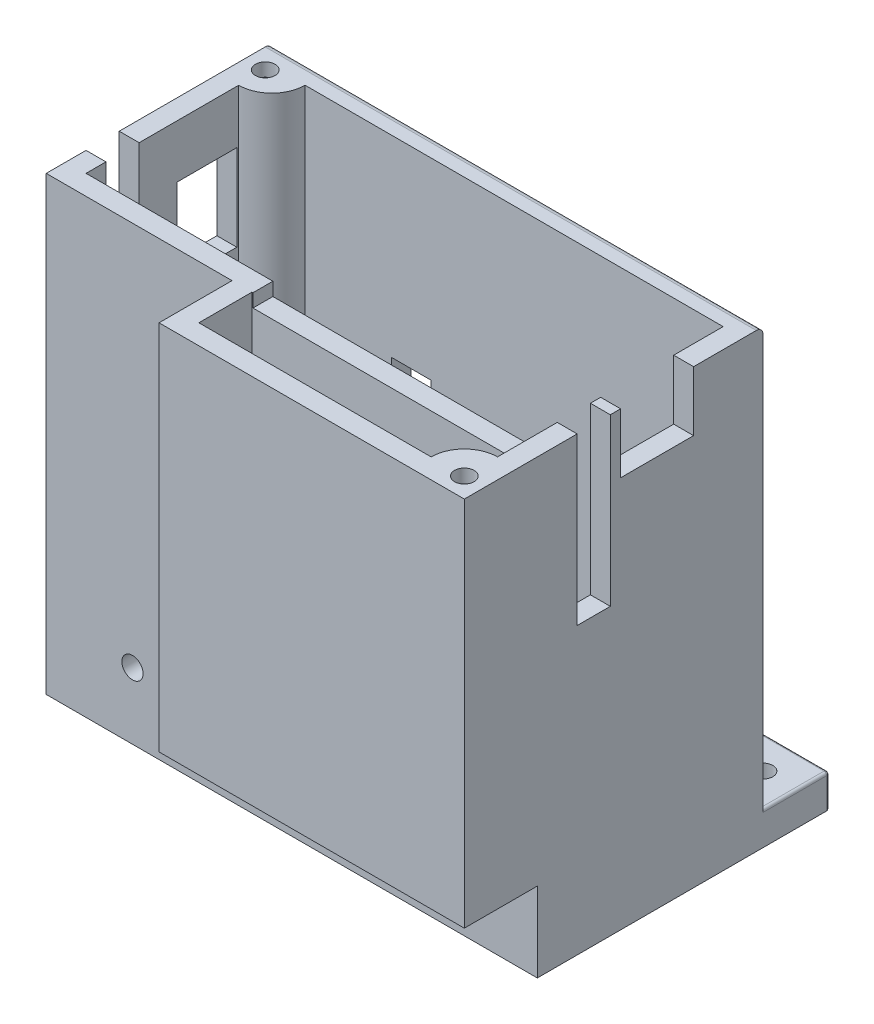
from build123d import *

# Parameters (mm, degrees)
SKETCH1_W            = 74
SKETCH1_H            = 45
BOSS_EXTRUDE1_DEPTH  = 68
SKETCH3_W            = 68
SKETCH3_H            = 39
CUT_EXTRUDE2_DEPTH   = 65
SKETCH13_W           = 68
SKETCH13_H           = 3
BOSS_EXTRUDE3_DEPTH  = 65
SKETCH14_W           = 5
SKETCH14_H           = 58
CUT_EXTRUDE5_DEPTH   = 23
SKETCH15_W           = 5
SKETCH15_H           = 25
CUT_EXTRUDE6_DEPTH   = 3
SKETCH18_R           = 1.6
CUT_EXTRUDE8_DEPTH   = 3
SKETCH20_R           = 4
CUT_EXTRUDE9_DEPTH   = 18
BOSS_EXTRUDE4_DEPTH  = 68
SKETCH23_R           = 1.6
CUT_EXTRUDE10_DEPTH  = 66
BOSS_EXTRUDE5_DEPTH  = 68
SKETCH25_R           = 1.6
CUT_EXTRUDE11_DEPTH  = 66
FILLET2_R            = 1
SKETCH30_W           = 10
SKETCH30_H           = 5
BOSS_EXTRUDE6_DEPTH  = 10
SKETCH33_R           = 1.48
CUT_EXTRUDE13_DEPTH  = 5
SKETCH34_W           = 10
SKETCH34_H           = 5
BOSS_EXTRUDE8_DEPTH  = 10
SKETCH35_R           = 1.48
CUT_EXTRUDE14_DEPTH  = 5
FILLET10_R           = 0.4
CUT_EXTRUDE17_DEPTH  = 11
SKETCH45_W           = 3
SKETCH45_H           = 56
BOSS_EXTRUDE9_DEPTH  = 11
SKETCH47_W           = 46
SKETCH47_H           = 3
BOSS_EXTRUDE10_DEPTH = 11
SKETCH49_R           = 1.48
CUT_EXTRUDE18_DEPTH  = 56
SKETCH50_R           = 1.48
CUT_EXTRUDE19_DEPTH  = 68
SKETCH52_W           = 39.849234896
SKETCH52_H           = 2
CUT_EXTRUDE20_DEPTH  = 3
SKETCH54_W           = 11
SKETCH54_H           = 9
CUT_EXTRUDE21_DEPTH  = 3
SKETCH56_W           = 9
SKETCH56_H           = 13
CUT_EXTRUDE22_DEPTH  = 3
SKETCH57_W           = 6
SKETCH57_H           = 6
CUT_EXTRUDE23_DEPTH  = 3


with BuildPart() as part:
    # Sketch1 → Boss-Extrude1 (new body)
    with BuildSketch(Plane(origin=(-3.580186039, 0, -14.417736579), x_dir=(1, 0, 0), z_dir=(0, 1, 0))):
        with Locations((12.716824493, 5.25)):
            Rectangle(SKETCH1_W, SKETCH1_H)
    extrude(amount=BOSS_EXTRUDE1_DEPTH)

    # Sketch3 → Cut-Extrude2 (cut)
    with BuildSketch(Plane(origin=(-3.580186039, 68, -14.417736579), x_dir=(1, 0, 0), z_dir=(0, 1, 0))):
        with Locations((12.716824493, 5.25)):
            Rectangle(SKETCH3_W, SKETCH3_H)
    extrude(amount=-CUT_EXTRUDE2_DEPTH, mode=Mode.SUBTRACT)

    # Sketch13 → Boss-Extrude3 (add)
    with BuildSketch(Plane(origin=(-3.580186039, 3, -14.417736579), x_dir=(1, 0, 0), z_dir=(0, 1, 0))):
        with Locations((12.716824493, -4.75)):
            Rectangle(SKETCH13_W, SKETCH13_H)
    extrude(amount=BOSS_EXTRUDE3_DEPTH)

    # Sketch14 → Cut-Extrude5 (cut)
    with BuildSketch(Plane(origin=(-27.863361546, 0, -14.417736579), x_dir=(0, 0, 1), z_dir=(-1, 0, 0))):
        with Locations((-2.25, 39)):
            Rectangle(SKETCH14_W, SKETCH14_H)
    extrude(amount=-CUT_EXTRUDE5_DEPTH, mode=Mode.SUBTRACT)

    # Sketch15 → Cut-Extrude6 (cut)
    with BuildSketch(Plane(origin=(46.136638454, 0, -14.417736579), x_dir=(0, 0, -1), z_dir=(1, 0, 0))):
        with Locations((2.25, 55.5)):
            Rectangle(SKETCH15_W, SKETCH15_H)
    extrude(amount=-CUT_EXTRUDE6_DEPTH, mode=Mode.SUBTRACT)

    # Sketch18 → Cut-Extrude8 (cut)
    with BuildSketch(Plane(origin=(-3.580186039, 0, -11.167736579), x_dir=(-1, 0, 0), z_dir=(0, 0, -1))):
        with Locations((11.283175507, 10)):
            Circle(SKETCH18_R)
    extrude(amount=-CUT_EXTRUDE8_DEPTH, mode=Mode.SUBTRACT)

    # Sketch20 → Cut-Extrude9 (cut)
    with BuildSketch(Plane(origin=(0, 0, -42.167736579), x_dir=(-1, 0, 0), z_dir=(0, 0, -1))):
        with Locations((9.863361546, 8)):
            Circle(SKETCH20_R)
    extrude(amount=-CUT_EXTRUDE9_DEPTH, mode=Mode.SUBTRACT)

    # Sketch21 → Boss-Extrude4 (add)
    with BuildSketch(Plane.XZ):
        with BuildLine():
            Line((46.136638454, -4.167736579), (46.136638454, 2.832263421))
            Line((46.136638454, 2.832263421), (39.136638454, 2.832263421))
            ThreePointArc((39.136638454, 2.832263421), (39.601104548, -3.703270485), (46.136638454, -4.167736579))
        make_face()
    extrude(amount=-BOSS_EXTRUDE4_DEPTH)

    # Sketch23 → Cut-Extrude10 (cut)
    with BuildSketch(Plane.XZ):
        with Locations((43.136638454, -0.167736579)):
            Circle(SKETCH23_R)
    extrude(amount=-CUT_EXTRUDE10_DEPTH, mode=Mode.SUBTRACT)

    # Sketch24 → Boss-Extrude5 (add)
    with BuildSketch(Plane.XZ):
        with BuildLine():
            Line((-20.863361546, -42.167736579), (-27.863361546, -42.167736579))
            Line((-27.863361546, -42.167736579), (-27.863361546, -35.167736579))
            ThreePointArc((-27.863361546, -35.167736579), (-21.327827641, -35.632202673), (-20.863361546, -42.167736579))
        make_face()
    extrude(amount=-BOSS_EXTRUDE5_DEPTH)

    # Sketch25 → Cut-Extrude11 (cut)
    with BuildSketch(Plane.XZ):
        with Locations((-24.863361546, -39.167736579)):
            Circle(SKETCH25_R)
    extrude(amount=-CUT_EXTRUDE11_DEPTH, mode=Mode.SUBTRACT)

    # Fillet2
    fillet2_edges = [part.edges().sort_by_distance(p)[0] for p in [
        (9.136638454, 68, -42.167736579),
    ]]
    fillet(fillet2_edges, radius=FILLET2_R)

    # Sketch30 → Boss-Extrude6 (add)
    with BuildSketch(Plane(origin=(0, 0, -42.167736579), x_dir=(-1, 0, 0), z_dir=(0, 0, -1))):
        with Locations((-41.136638454, 2.5)):
            Rectangle(SKETCH30_W, SKETCH30_H)
    extrude(amount=BOSS_EXTRUDE6_DEPTH)

    # Sketch33 → Cut-Extrude13 (cut)
    with BuildSketch(Plane.XZ):
        with Locations((41.136638454, -47.167736579)):
            Circle(SKETCH33_R)
    extrude(amount=-CUT_EXTRUDE13_DEPTH, mode=Mode.SUBTRACT)

    # Sketch34 → Boss-Extrude8 (add)
    with BuildSketch(Plane(origin=(0, 0, -42.167736579), x_dir=(-1, 0, 0), z_dir=(0, 0, -1))):
        with Locations((22.863361546, 2.5)):
            Rectangle(SKETCH34_W, SKETCH34_H)
    extrude(amount=BOSS_EXTRUDE8_DEPTH)

    # Sketch35 → Cut-Extrude14 (cut)
    with BuildSketch(Plane.XZ):
        with Locations((-22.863361546, -47.167736579)):
            Circle(SKETCH35_R)
    extrude(amount=-CUT_EXTRUDE14_DEPTH, mode=Mode.SUBTRACT)

    # Fillet10
    fillet10_edges = [part.edges().sort_by_distance(p)[0] for p in [
        (46.136638454, 5, -47.167736579),
        (36.136638454, 0, -47.167736579),
        (36.136638454, 5, -47.167736579),
        (46.136638454, 2.5, -52.167736579),
        (41.136638454, 0, -52.167736579),
        (36.136638454, 2.5, -52.167736579),
        (41.136638454, 5, -52.167736579),
        (-17.863361546, 5, -47.167736579),
        (-17.863361546, 0, -47.167736579),
        (-17.863361546, 2.5, -52.167736579),
        (-22.863361546, 0, -52.167736579),
        (-22.863361546, 5, -52.167736579),
    ]]
    fillet(fillet10_edges, radius=FILLET10_R)

    # Sketch43 → Cut-Extrude17 (cut)
    with BuildSketch(Plane.XY.offset(2.832263421)):
        Polygon((-27.863361546, 68), (0.136638454, 68), (0.136638454, 12), (46.136638454, 12), (46.136638454, 0), (-27.863361546, 0), (-27.863361546, 12), align=None)
    extrude(amount=-CUT_EXTRUDE17_DEPTH, mode=Mode.SUBTRACT)

    # Sketch45 → Boss-Extrude9 (add)
    with BuildSketch(Plane.XY.offset(2.832263421)):
        with Locations((1.636638454, 40)):
            Rectangle(SKETCH45_W, SKETCH45_H)
    extrude(amount=-BOSS_EXTRUDE9_DEPTH)

    # Sketch47 → Boss-Extrude10 (add)
    with BuildSketch(Plane.XY.offset(2.832263421)):
        with Locations((23.136638454, 13.5)):
            Rectangle(SKETCH47_W, SKETCH47_H)
    extrude(amount=-BOSS_EXTRUDE10_DEPTH)

    # Sketch49 → Cut-Extrude18 (cut)
    with BuildSketch(Plane(origin=(0, 68, 0), x_dir=(1, 0, 0), z_dir=(0, 1, 0))):
        with Locations((43.136638454, 0.167736579)):
            Circle(SKETCH49_R)
    extrude(amount=-CUT_EXTRUDE18_DEPTH, mode=Mode.SUBTRACT)

    # Sketch50 → Cut-Extrude19 (cut)
    with BuildSketch(Plane(origin=(0, 68, 0), x_dir=(1, 0, 0), z_dir=(0, 1, 0))):
        with Locations((-24.863361546, 38.167736579)):
            Circle(SKETCH50_R)
    extrude(amount=-CUT_EXTRUDE19_DEPTH, mode=Mode.SUBTRACT)

    # Sketch52 → Cut-Extrude20 (cut)
    with BuildSketch(Plane(origin=(0, 0, -11.167736579), x_dir=(-1, 0, 0), z_dir=(0, 0, -1))):
        with Locations((-23.212021006, 67)):
            Rectangle(SKETCH52_W, SKETCH52_H)
    extrude(amount=-CUT_EXTRUDE20_DEPTH, mode=Mode.SUBTRACT)

    # Sketch54 → Cut-Extrude21 (cut)
    with BuildSketch(Plane(origin=(46.136638454, 0, 0), x_dir=(0, 0, -1), z_dir=(1, 0, 0))):
        with Locations((26.2154696, 63.5)):
            Rectangle(SKETCH54_W, SKETCH54_H)
    extrude(amount=-CUT_EXTRUDE21_DEPTH, mode=Mode.SUBTRACT)

    # Sketch56 → Cut-Extrude22 (cut)
    with BuildSketch(Plane.ZY.offset(27.863361546)):
        with Locations((-29.387336529, 53.5)):
            Rectangle(SKETCH56_W, SKETCH56_H)
    extrude(amount=-CUT_EXTRUDE22_DEPTH, mode=Mode.SUBTRACT)

    # Sketch57 → Cut-Extrude23 (cut)
    with BuildSketch(Plane(origin=(0, 0, -42.167736579), x_dir=(-1, 0, 0), z_dir=(0, 0, -1))):
        with Locations((3.863361546, 36)):
            Rectangle(SKETCH57_W, SKETCH57_H)
    extrude(amount=-CUT_EXTRUDE23_DEPTH, mode=Mode.SUBTRACT)


solid = part.part
